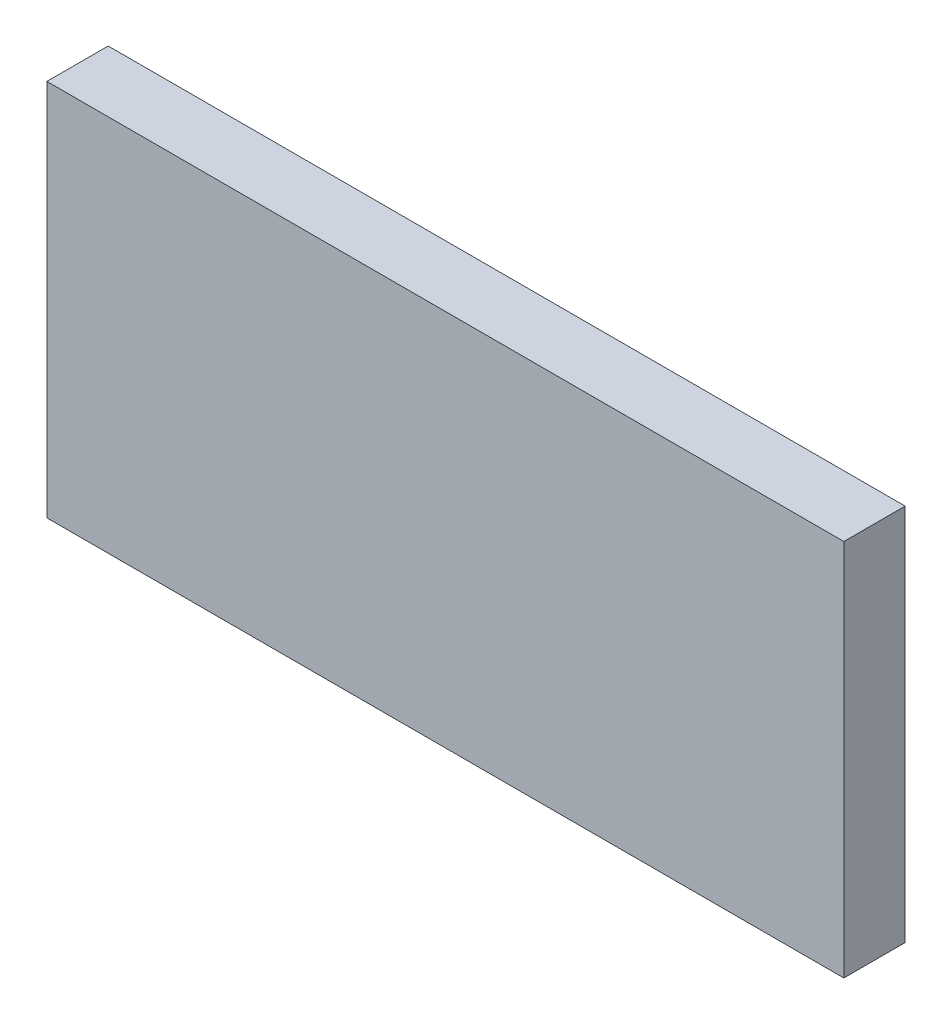
from build123d import *

# Parameters (mm, degrees)
SKETCH1_W           = 39
SKETCH1_H           = 18.5
BOSS_EXTRUDE1_DEPTH = 3


with BuildPart() as part:
    # Sketch1 → Boss-Extrude1 (new body)
    with BuildSketch(Plane.XY):
        with Locations((19.5, 9.25)):
            Rectangle(SKETCH1_W, SKETCH1_H)
    extrude(amount=BOSS_EXTRUDE1_DEPTH)


solid = part.part
